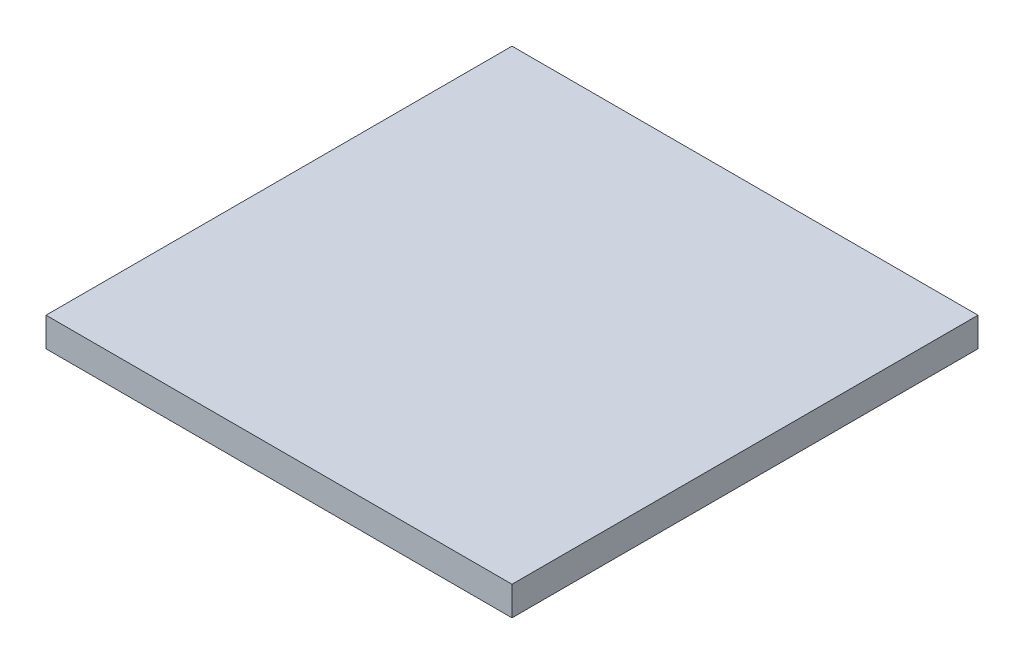
from build123d import *

# Parameters (mm, degrees)
SKETCH1_W           = 76.2
SKETCH1_H           = 76.2
BOSS_EXTRUDE1_DEPTH = 4.7625


with BuildPart() as part:
    # Sketch1 → Boss-Extrude1 (new body)
    with BuildSketch(Plane(origin=(0, 0, 0), x_dir=(1, 0, 0), z_dir=(0, 1, 0))):
        with Locations((38.1, -38.1)):
            Rectangle(SKETCH1_W, SKETCH1_H)
    extrude(amount=BOSS_EXTRUDE1_DEPTH)


solid = part.part
